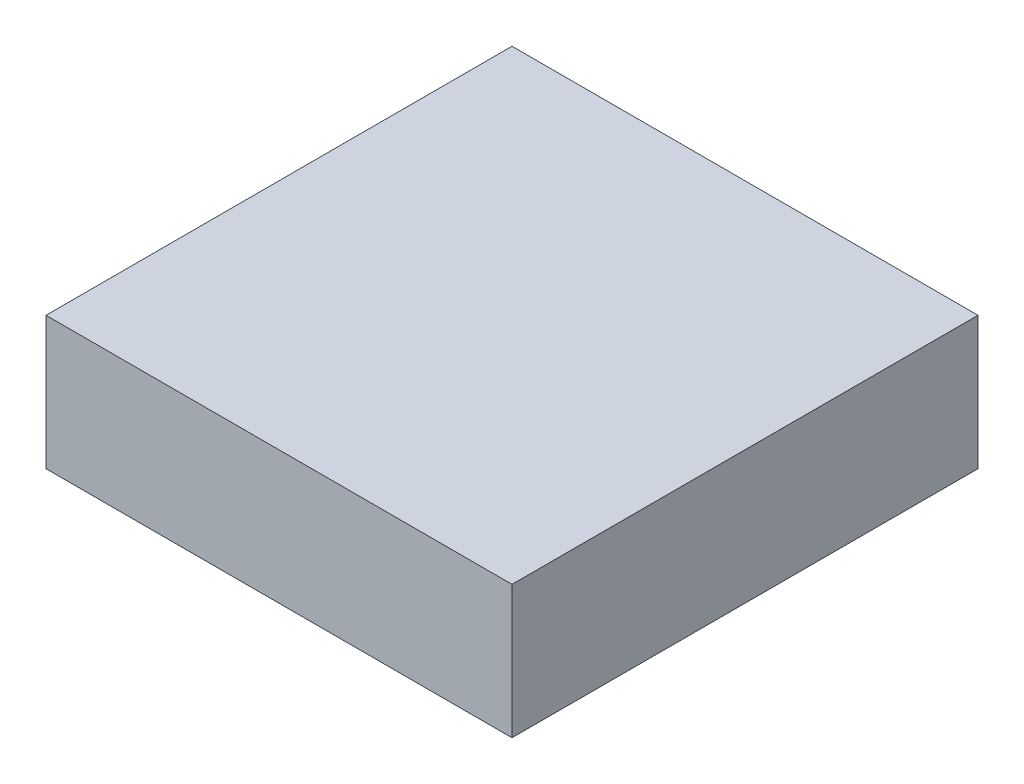
from build123d import *

# Parameters (mm, degrees)
CROQUIS1_W              = 98.2
CROQUIS1_H              = 98.2
SALIENTE_EXTRUIR2_DEPTH = 28
CROQUIS2_W              = 90.2
CROQUIS2_H              = 90.2
CORTAR_EXTRUIR1_DEPTH   = 24
CROQUIS3_W              = 2.6
CROQUIS3_H              = 35
SALIENTE_EXTRUIR3_DEPTH = 22
CROQUIS5_W              = 2.6
CROQUIS5_H              = 35
SALIENTE_EXTRUIR4_DEPTH = 22


with BuildPart() as part:
    # Croquis1 → Saliente-Extruir2 (new body)
    with BuildSketch(Plane(origin=(0, 0, 0), x_dir=(1, 0, 0), z_dir=(0, 1, 0))):
        Rectangle(CROQUIS1_W, CROQUIS1_H)
    extrude(amount=-SALIENTE_EXTRUIR2_DEPTH)

    # Croquis2 → Cortar-Extruir1 (cut)
    with BuildSketch(Plane.XZ.offset(28)):
        Rectangle(CROQUIS2_W, CROQUIS2_H)
    extrude(amount=-CORTAR_EXTRUIR1_DEPTH, mode=Mode.SUBTRACT)

    # Croquis3 → Saliente-Extruir3 (add)
    with BuildSketch(Plane.XZ.offset(4)):
        with Locations((-14.3, -6.4)):
            Rectangle(CROQUIS3_W, CROQUIS3_H)
    extrude(amount=SALIENTE_EXTRUIR3_DEPTH)

    # Croquis5 → Saliente-Extruir4 (add)
    with BuildSketch(Plane.XZ.offset(4)):
        with Locations((15.49, -6.4)):
            Rectangle(CROQUIS5_W, CROQUIS5_H)
    extrude(amount=SALIENTE_EXTRUIR4_DEPTH)


solid = part.part
